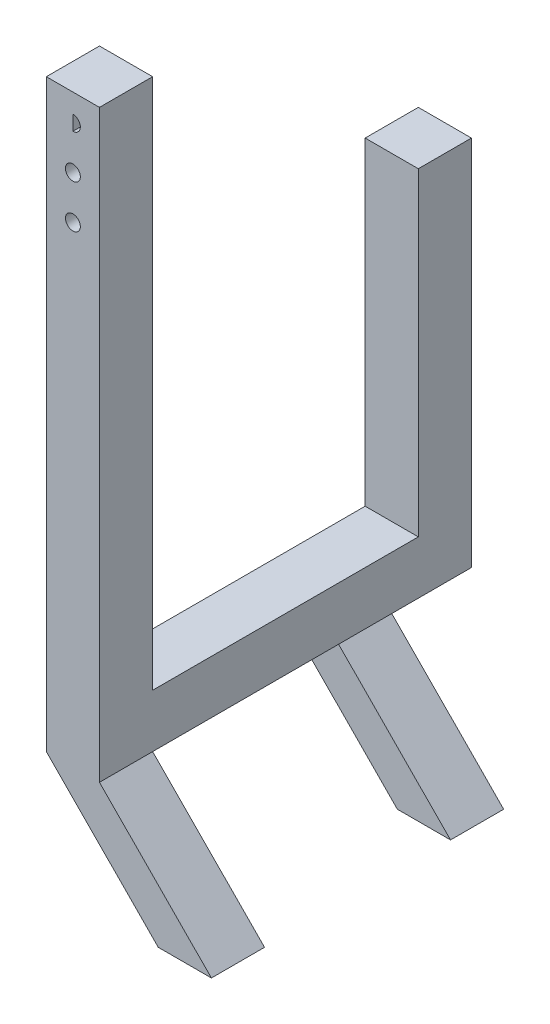
from build123d import *

# Parameters (mm, degrees)
SKETCH1_W           = 12.7
SKETCH1_H           = 139.7
BOSS_EXTRUDE1_DEPTH = 12.7
SKETCH2_W           = 63.5
SKETCH2_H           = 12.7
BOSS_EXTRUDE2_DEPTH = 12.7
SKETCH3_W           = 12.7
SKETCH3_H           = 88.9
BOSS_EXTRUDE3_DEPTH = 12.7
BOSS_EXTRUDE5_DEPTH = 12.7
BOSS_EXTRUDE6_START = -19.05
BOSS_EXTRUDE6_DEPTH = 12.7
SKETCH6_R           = 1.778
CUT_EXTRUDE1_DEPTH  = 89.9


with BuildPart() as part:
    # Sketch1 → Boss-Extrude1 (new body)
    with BuildSketch(Plane.XY):
        with Locations((6.35, 69.85)):
            Rectangle(SKETCH1_W, SKETCH1_H)
    extrude(amount=BOSS_EXTRUDE1_DEPTH)

    # Sketch2 → Boss-Extrude2 (add)
    with BuildSketch(Plane.ZY):
        with Locations((-31.75, 6.35)):
            Rectangle(SKETCH2_W, SKETCH2_H)
    extrude(amount=-BOSS_EXTRUDE2_DEPTH)

    # Sketch3 → Boss-Extrude3 (add)
    with BuildSketch(Plane.ZY):
        with Locations((-69.85, 44.45)):
            Rectangle(SKETCH3_W, SKETCH3_H)
    extrude(amount=-BOSS_EXTRUDE3_DEPTH)

    # Sketch4 → Boss-Extrude5 (add)
    with BuildSketch(Plane.XY.offset(12.7)):
        Polygon((12.7, 0), (39.453062828, -27.127175108), (26.753062828, -27.127175108), (0, 0), align=None)
    extrude(amount=-BOSS_EXTRUDE5_DEPTH)

    # Sketch5 → Boss-Extrude6 (add)
    with BuildSketch(Plane(origin=(0, 0, -76.2), x_dir=(-1, 0, 0), z_dir=(0, 0, -1)).offset(BOSS_EXTRUDE6_START)):
        Polygon((0, 0), (-26.753062828, -27.127175108), (-39.453062828, -27.127175108), (-12.7, 0), align=None)
    extrude(amount=-BOSS_EXTRUDE6_DEPTH)

    # Sketch6 → Cut-Extrude1 (cut, through all)
    with BuildSketch(Plane.XY.offset(12.7)):
        with BuildLine():
            ThreePointArc((6.35, 131.572), (8.128, 133.35), (6.35, 135.128))
            Line((6.35, 135.128), (6.35, 131.572))
        make_face()
        with Locations((6.35, 112.7125)):
            Circle(SKETCH6_R)
        with Locations((6.35, 123.03125)):
            Circle(SKETCH6_R)
    extrude(amount=-CUT_EXTRUDE1_DEPTH, mode=Mode.SUBTRACT)


solid = part.part
